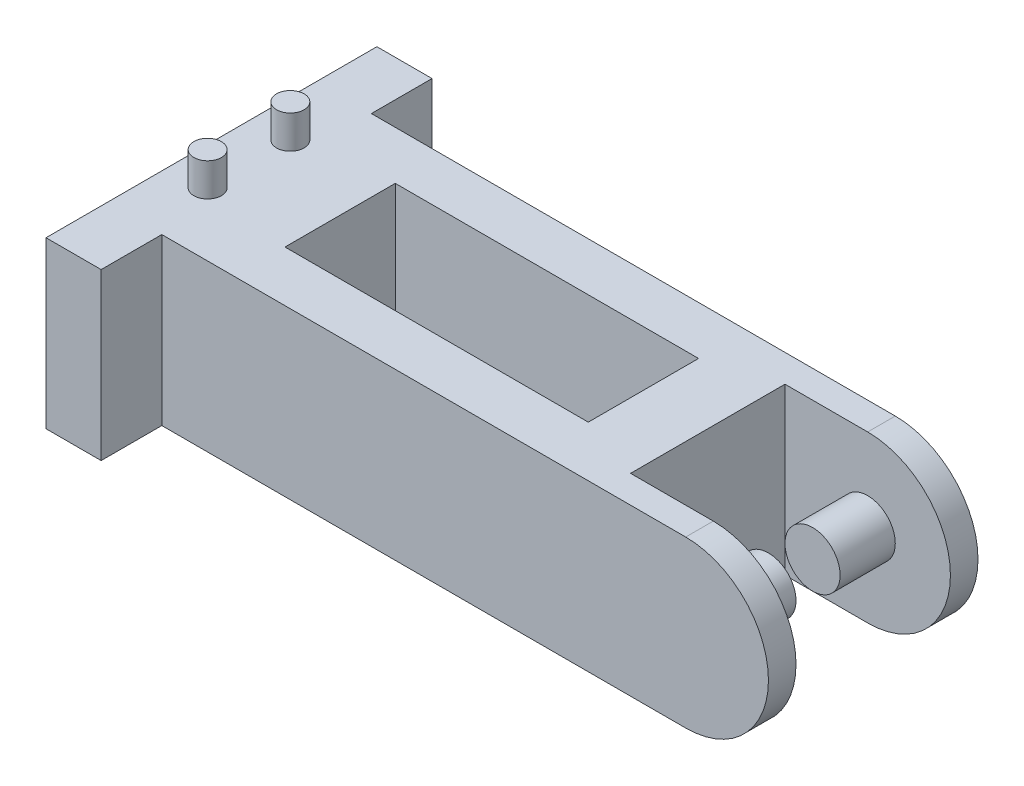
from build123d import *

# Parameters (mm, degrees)
BOSS_EXTRUDE1_DEPTH      = 15
BOSS_EXTRUDE1_DEPTH_BACK = 15
CUT_EXTRUDE1_DEPTH       = 38
SKETCH6_W                = 55
SKETCH6_H                = 20
CUT_EXTRUDE2_DEPTH       = 38
SKETCH8_R                = 5
BOSS_EXTRUDE2_DEPTH      = 10
SKETCH9_R                = 2.5
BOSS_EXTRUDE3_DEPTH      = 6


with BuildPart() as part:
    # Sketch1 → Boss-Extrude1 (new, two sides: drawn at the far end of the back side and taken through both)
    with BuildSketch(Plane(origin=(0, 0, 0), x_dir=(1, 0, 0), z_dir=(0, 1, 0)).offset(-BOSS_EXTRUDE1_DEPTH_BACK)):
        Polygon((-13.124974518, 30), (-13.124974518, 19), (96.875025482, 19), (96.875025482, 14), (66.875025482, 14), (66.875025482, -14), (96.875025482, -14), (96.875025482, -19), (-13.124974518, -19), (-13.124974518, -30), (-23.124974518, -30), (-23.124974518, 30), align=None)
    extrude(amount=BOSS_EXTRUDE1_DEPTH + BOSS_EXTRUDE1_DEPTH_BACK)

    # Sketch4 → Cut-Extrude1 (cut)
    with BuildSketch(Plane.XY.offset(19)):
        with BuildLine():
            Line((96.875025482, -15), (96.875025482, 0))
            ThreePointArc((96.875025482, 0), (92.4816272, -10.606601718), (81.875025482, -15))
            Line((81.875025482, -15), (96.875025482, -15))
        make_face()
        with BuildLine():
            Line((96.875025482, 15), (81.875025482, 15))
            ThreePointArc((81.875025482, 15), (92.4816272, 10.606601718), (96.875025482, 0))
            Line((96.875025482, 0), (96.875025482, 15))
        make_face()
    extrude(amount=-CUT_EXTRUDE1_DEPTH, mode=Mode.SUBTRACT)

    # Sketch6 → Cut-Extrude2 (cut)
    with BuildSketch(Plane(origin=(0, 15, 0), x_dir=(1, 0, 0), z_dir=(0, 1, 0))):
        with Locations((27.5, 0.205975337)):
            Rectangle(SKETCH6_W, SKETCH6_H)
    extrude(amount=-CUT_EXTRUDE2_DEPTH, mode=Mode.SUBTRACT)

    # Sketch8 → Boss-Extrude2 (add)
    with BuildSketch(Plane(origin=(0, 0, 14), x_dir=(-1, 0, 0), z_dir=(0, 0, -1))):
        with Locations((-81.875025482, 0)):
            Circle(SKETCH8_R)
    boss_extrude2 = extrude(amount=BOSS_EXTRUDE2_DEPTH)

    # Mirror1: Boss-Extrude2 across plane
    add(boss_extrude2.mirror(Plane.XY))

    # Sketch9 → Boss-Extrude3 (add)
    with BuildSketch(Plane(origin=(0, 15, 0), x_dir=(1, 0, 0), z_dir=(0, 1, 0))):
        with Locations((-16.320792203, 7.5)):
            Circle(SKETCH9_R)
        with Locations((-16.320792203, -7.5)):
            Circle(SKETCH9_R)
    extrude(amount=BOSS_EXTRUDE3_DEPTH)


solid = part.part
